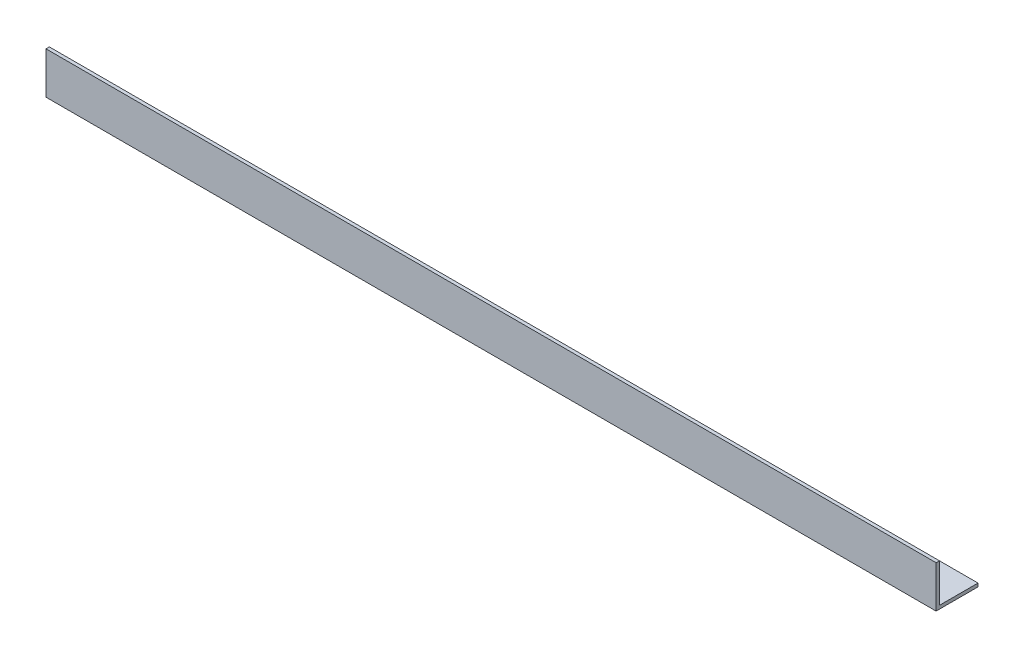
from build123d import *

# Parameters (mm, degrees)
EXTRUDE_1_DEPTH = 531


with BuildPart() as part:
    # Эскиз1 → Вытянуть-Тонкостенный1 (new body)
    with BuildSketch(Plane(origin=(0, 0, 0), x_dir=(0, 0, -1), z_dir=(1, 0, 0))):
        Polygon((0, 25), (0, 0), (25, 0), (25, 2), (2, 2), (2, 25), align=None)
    extrude(amount=EXTRUDE_1_DEPTH)


solid = part.part
